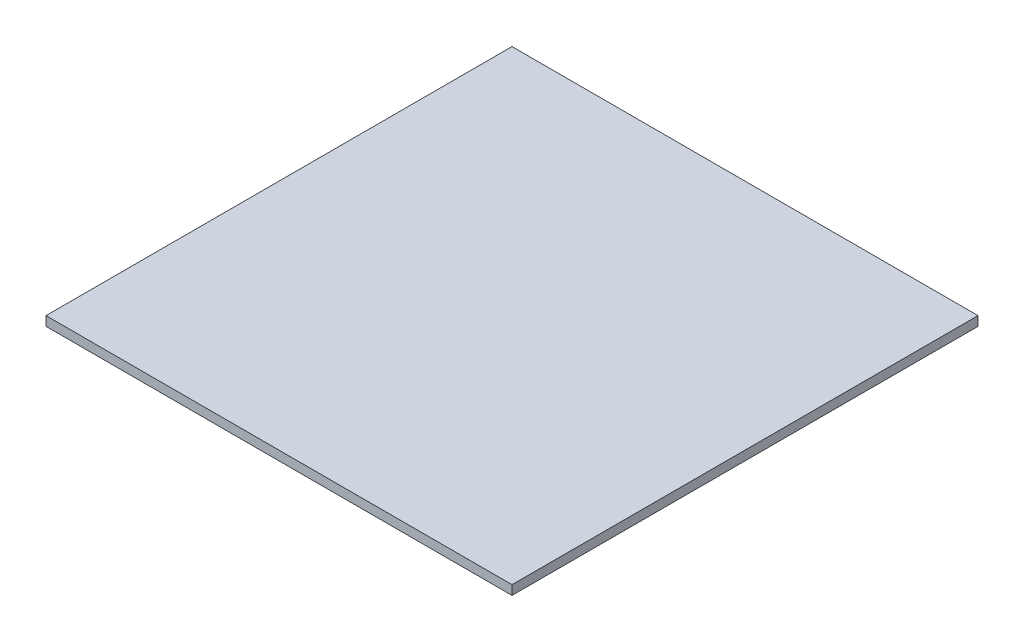
from build123d import *

# Parameters (mm, degrees)
SKETCH1_W           = 150
SKETCH1_H           = 150
BOSS_EXTRUDE1_DEPTH = 3


with BuildPart() as part:
    # Sketch1 → Boss-Extrude1 (new body)
    with BuildSketch(Plane(origin=(0, 0, 0), x_dir=(1, 0, 0), z_dir=(0, 1, 0))):
        with Locations((86.370613928, 55.73070589)):
            Rectangle(SKETCH1_W, SKETCH1_H)
    extrude(amount=BOSS_EXTRUDE1_DEPTH)


solid = part.part
